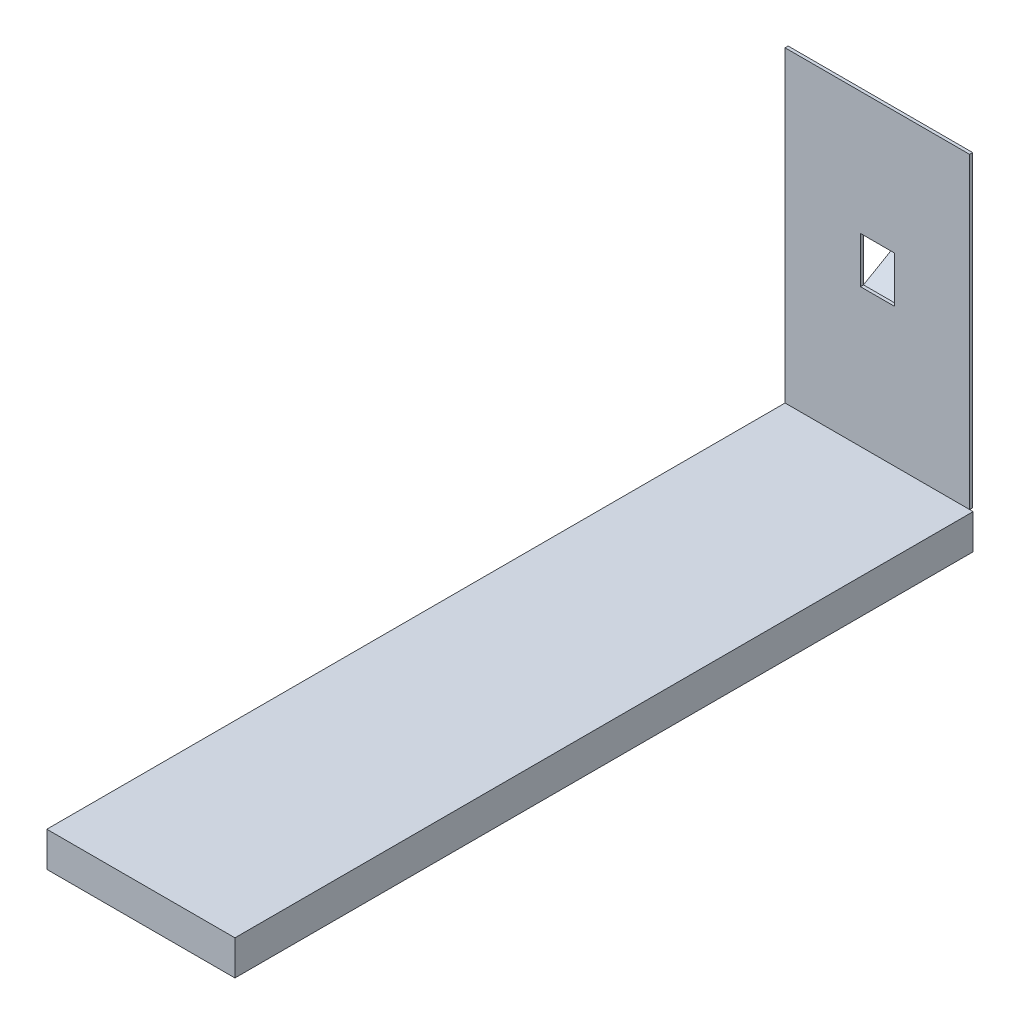
from build123d import *

# Parameters (mm, degrees)
SKETCH1_W           = 1200
SKETCH1_H           = 2000
BOSS_EXTRUDE1_DEPTH = 20
SKETCH3_W           = 220
SKETCH3_H           = 300
CUT_EXTRUDE1_DEPTH  = 21
BOSS_EXTRUDE2_DEPTH = 110
SKETCH7_W           = 1223.00766722
SKETCH7_H           = 226.240360044
BOSS_EXTRUDE3_DEPTH = 4799.571529182


with BuildPart() as part:
    # Sketch1 → Boss-Extrude1 (new body)
    with BuildSketch(Plane.XY):
        Rectangle(SKETCH1_W, SKETCH1_H)
    extrude(amount=BOSS_EXTRUDE1_DEPTH)

    # Sketch3 → Cut-Extrude1 (cut, through all)
    with BuildSketch(Plane.XY.offset(20)):
        with Locations((0, 50)):
            Rectangle(SKETCH3_W, SKETCH3_H)
    extrude(amount=-CUT_EXTRUDE1_DEPTH, mode=Mode.SUBTRACT)

    # Sketch4 → Boss-Extrude2 (add, symmetric)
    with BuildSketch(Plane(origin=(0, 0, 0), x_dir=(0, 0, -1), z_dir=(1, 0, 0))):
        Polygon((0, -100), (254, 46.646968374), (254, 35.09996299), (5, -108.660254038), (0, -111.547005384), align=None)
    extrude(amount=BOSS_EXTRUDE2_DEPTH, both=True)


with BuildPart() as body_2:
    # Sketch7 → Boss-Extrude3 (new body)
    with BuildSketch(Plane.XY.offset(20)):
        with Locations((11.50383361, -1113.120180022)):
            Rectangle(SKETCH7_W, SKETCH7_H)
    extrude(amount=BOSS_EXTRUDE3_DEPTH)


solid = Compound([part.part, body_2.part])
